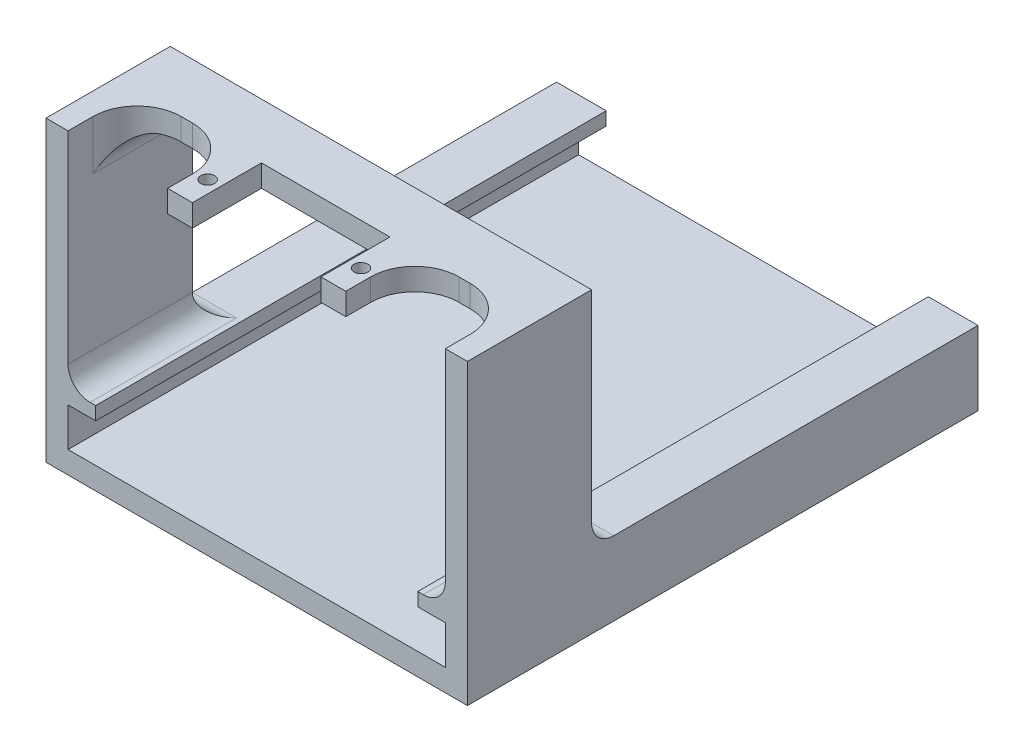
from build123d import *

# Parameters (mm, degrees)
EXTRUDE_7_DEPTH      = 5
EXTRUDE_7_DEPTH_BACK = 5
SKETCH_1_W           = 76.35
SKETCH_1_H           = 54
EXTRUDE_8_DEPTH      = 12.5
EXTRUDE_8_DEPTH_BACK = 80
SKETCH_3_W           = 4.5
SKETCH_3_H           = 4
SKETCH_3_W_2         = 4
SKETCH_3_H_2         = 40.6
EXTRUDE_9_DEPTH      = 12.5
SKETCH_5_R           = 1.25
CUT_EXTRUDE_1_DEPTH  = 12.5
FILLET_1_R           = 4
FILLET_2_R           = 4
FILLET_3_R           = 8
FILLET_4_R           = 8
FILLET_5_R           = 8
FILLET_6_R           = 8
FILLET_7_R           = 5
FILLET_8_R           = 5
FILLET_9_R           = 4
FILLET_10_R          = 4


with BuildPart() as part:
    # Эскиз1 → Бобышка-Вытянуть7 (new, two sides: drawn at the far end of the back side and taken through both)
    with BuildSketch(Plane.XY.offset(-EXTRUDE_7_DEPTH_BACK)):
        with Locations((38.175, -23)):
            Rectangle(SKETCH_1_W, SKETCH_1_H)
        Polygon((72.35, 0), (72.35, -36.6), (67.35, -36.6), (67.35, -39), (72.35, -39), (72.35, -46), (4, -46), (4, -39), (9, -39), (9, -36.6), (4, -36.6), (4, 0), align=None, mode=Mode.SUBTRACT)
    extrude(amount=EXTRUDE_7_DEPTH + EXTRUDE_7_DEPTH_BACK)

    # Эскиз2 → Бобышка-Вытянуть8 (add, two sides: drawn at the far end of the back side and taken through both)
    with BuildSketch(Plane.XY.offset(5).offset(-EXTRUDE_8_DEPTH_BACK)):
        Polygon((4, -46), (4, -39), (9, -39), (9, -36.6), (4, -36.6), (0, -36.6), (0, -50), (76.35, -50), (76.35, -36.6), (72.35, -36.6), (67.35, -36.6), (67.35, -39), (72.35, -39), (72.35, -46), align=None)
    extrude(amount=EXTRUDE_8_DEPTH + EXTRUDE_8_DEPTH_BACK)

    # Эскиз3 → Бобышка-Вытянуть9 (add)
    with BuildSketch(Plane.XY.offset(5)):
        with Locations((52.065, 2)):
            Rectangle(SKETCH_3_W, SKETCH_3_H)
        with Locations((24.285, 2)):
            Rectangle(SKETCH_3_W, SKETCH_3_H)
        with Locations((2, -16.3)):
            Rectangle(SKETCH_3_W_2, SKETCH_3_H_2)
        with Locations((74.35, -16.3)):
            Rectangle(SKETCH_3_W_2, SKETCH_3_H_2)
    extrude(amount=EXTRUDE_9_DEPTH)

    # Эскиз5 → Вырез-Вытянуть1 (cut)
    with BuildSketch(Plane(origin=(0, 4, 0), x_dir=(1, 0, 0), z_dir=(0, 1, 0))):
        with Locations((24.285, -12.5)):
            Circle(SKETCH_5_R)
        with Locations((52.065, -12.5)):
            Circle(SKETCH_5_R)
    extrude(amount=-CUT_EXTRUDE_1_DEPTH, mode=Mode.SUBTRACT)

    # Скругление1
    fillet_1_edges = [part.edges().sort_by_distance(p)[0] for p in [
        (2, -36.6, -5),
    ]]
    fillet(fillet_1_edges, radius=FILLET_1_R)

    # Скругление2
    fillet_2_edges = [part.edges().sort_by_distance(p)[0] for p in [
        (74.35, -36.6, -5),
    ]]
    fillet(fillet_2_edges, radius=FILLET_2_R)

    # Скругление3
    fillet_3_edges = [part.edges().sort_by_distance(p)[0] for p in [
        (4, 2, 5),
    ]]
    fillet(fillet_3_edges, radius=FILLET_3_R)

    # Скругление4
    fillet_4_edges = [part.edges().sort_by_distance(p)[0] for p in [
        (72.35, 2, 5),
    ]]
    fillet(fillet_4_edges, radius=FILLET_4_R)

    # Скругление5
    fillet_5_edges = [part.edges().sort_by_distance(p)[0] for p in [
        (22.035, 2, 5),
    ]]
    fillet(fillet_5_edges, radius=FILLET_5_R)

    # Скругление6
    fillet_6_edges = [part.edges().sort_by_distance(p)[0] for p in [
        (54.315, 2, 5),
    ]]
    fillet(fillet_6_edges, radius=FILLET_6_R)

    # Скругление7
    fillet_7_edges = [part.edges().sort_by_distance(p)[0] for p in [
        (72.35, 0, 4),
    ]]
    fillet(fillet_7_edges, radius=FILLET_7_R)

    # Скругление8
    fillet_8_edges = [part.edges().sort_by_distance(p)[0] for p in [
        (4, 0, 4),
    ]]
    fillet(fillet_8_edges, radius=FILLET_8_R)

    # Скругление9
    fillet_9_edges = [part.edges().sort_by_distance(p)[0] for p in [
        (4, -36.6, 4.25),
    ]]
    fillet(fillet_9_edges, radius=FILLET_9_R)

    # Скругление10
    fillet_10_edges = [part.edges().sort_by_distance(p)[0] for p in [
        (72.35, -36.6, 4.25),
    ]]
    fillet(fillet_10_edges, radius=FILLET_10_R)


solid = part.part
